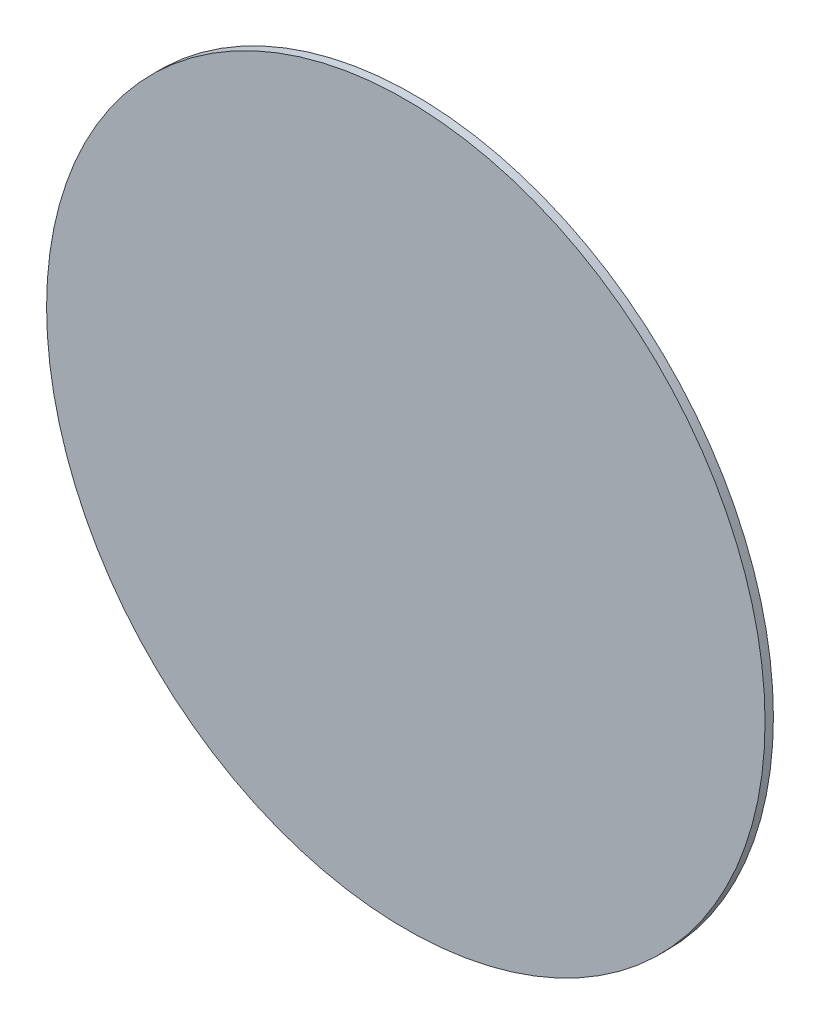
from build123d import *

# Parameters (mm, degrees)
SKETCH2_R           = 107.5
BOSS_EXTRUDE1_DEPTH = 2.5


with BuildPart() as part:
    # Sketch2 → Boss-Extrude1 (new body)
    with BuildSketch(Plane.XY):
        Circle(SKETCH2_R)
    extrude(amount=BOSS_EXTRUDE1_DEPTH)


solid = part.part
